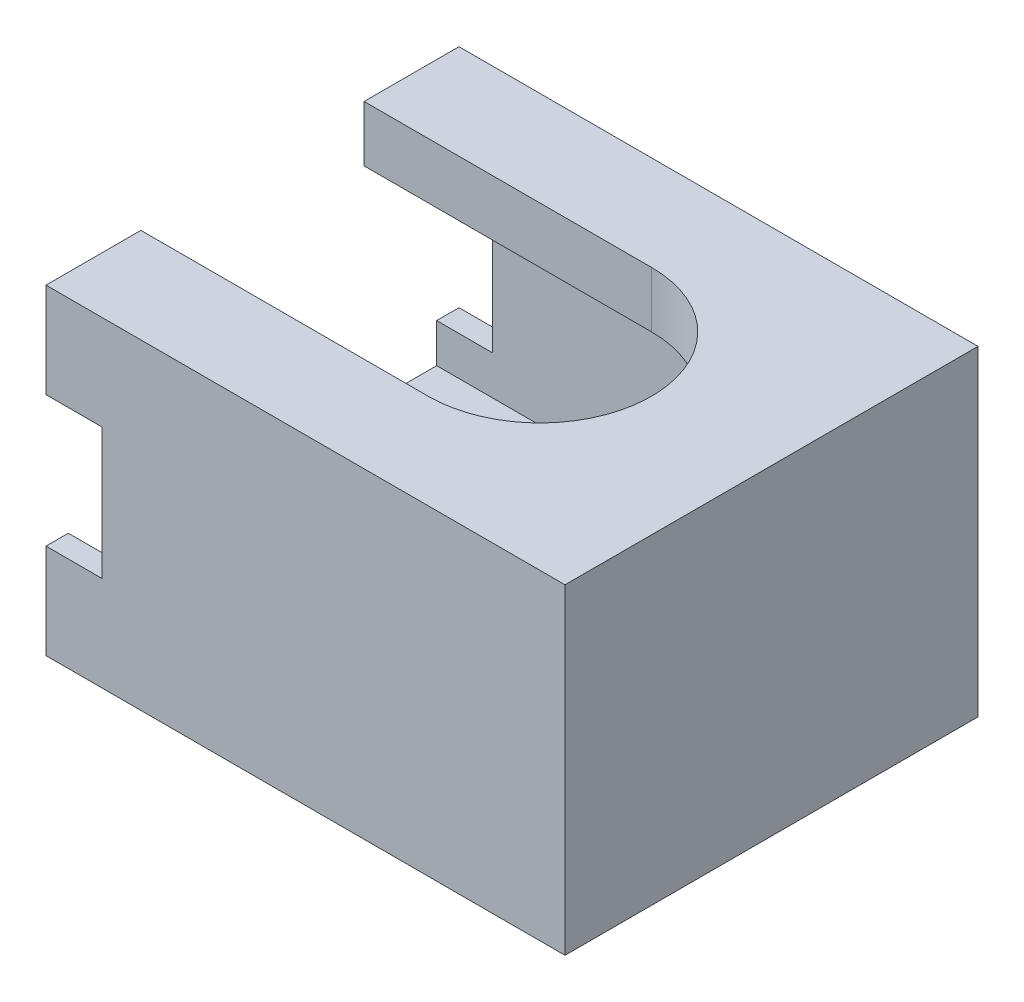
from build123d import *

# Parameters (mm, degrees)
BOSS_EXTRUDE1_DEPTH = 7.5
SKETCH4_W           = 16.6
SKETCH4_H           = 14.8
BOSS_EXTRUDE2_DEPTH = 2
BOSS_EXTRUDE3_DEPTH = 2
BOSS_EXTRUDE6_DEPTH = 2


with BuildPart() as part:
    # Sketch3 → Boss-Extrude1 (new body)
    with BuildSketch(Plane(origin=(0, 0, 0), x_dir=(1, 0, 0), z_dir=(0, 1, 0))):
        Polygon((8.3, -7.4), (8.3, 7.4), (-8.3, 7.4), (-8.3, 6.6), (-7.5, 6.6), (7.5, 6.6), (7.5, -6.6), (-7.5, -6.6), (-8.3, -6.6), (-8.3, -7.4), align=None)
    extrude(amount=BOSS_EXTRUDE1_DEPTH)

    # Sketch4 → Boss-Extrude2 (add)
    with BuildSketch(Plane.XZ):
        Rectangle(SKETCH4_W, SKETCH4_H)
    extrude(amount=BOSS_EXTRUDE2_DEPTH)

    # Sketch5 → Boss-Extrude3 (add)
    with BuildSketch(Plane(origin=(0, 7.5, 0), x_dir=(1, 0, 0), z_dir=(0, 1, 0))):
        with BuildLine():
            Line((-8.3, 4), (0, 4))
            ThreePointArc((0, 4), (4, 0), (0, -4))
            Line((0, -4), (-8.3, -4))
            Line((-8.3, -4), (-8.3, -7.4))
            Line((-8.3, -7.4), (8.3, -7.4))
            Line((8.3, -7.4), (8.3, 7.4))
            Line((8.3, 7.4), (-8.3, 7.4))
            Line((-8.3, 7.4), (-8.3, 4))
        make_face()
    extrude(amount=BOSS_EXTRUDE3_DEPTH)

    # Sketch8 → Boss-Extrude6 (add)
    with BuildSketch(Plane.ZY.offset(8.3)):
        Polygon((-4, 9.5), (-7.4, 9.5), (-7.4, 6.1), (-6.6, 6.1), (-6.6, 7.5), (-4, 7.5), align=None)
        Polygon((4, 9.5), (4, 7.5), (6.6, 7.5), (6.6, 6.1), (7.4, 6.1), (7.4, 9.5), align=None)
        Polygon((6.6, 1.4), (7.4, 1.4), (7.4, -2), (4, -2), (4, 0), (6.6, 0), align=None)
        Polygon((-7.4, 1.4), (-6.6, 1.4), (-6.6, 0), (-4, 0), (-4, -2), (-7.4, -2), align=None)
    extrude(amount=BOSS_EXTRUDE6_DEPTH)


solid = part.part
